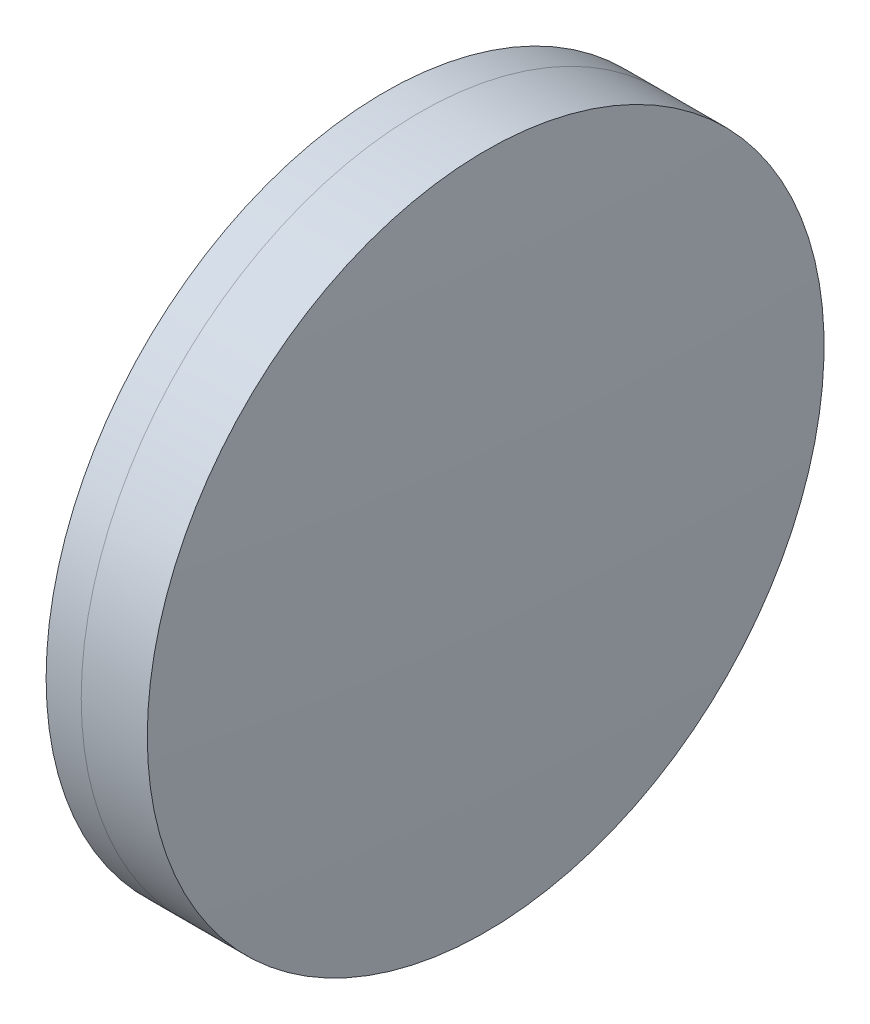
from build123d import *


with BuildPart() as part:
    # 草图1 one side → 旋转1 (revolve)
    with BuildSketch(Plane(origin=(0, 0, 0), x_dir=(1, 0, 0), z_dir=(0, 1, 0)), mode=Mode.PRIVATE) as revolve_1_sk:
        with BuildLine():
            ThreePointArc((77.514489477, 12.5), (76.920073035, 6.262558669), (76.721668974, 0))
            Line((76.721668974, 0), (80.021668974, 0))
            ThreePointArc((80.021668974, 0), (79.718324925, 6.279240278), (78.811117917, 12.5))
            Line((78.811117917, 12.5), (77.514489477, 12.5))
        make_face()
    revolve(revolve_1_sk.sketch.rotate(Axis((-9.702612178, 0, 0), (1, 0, 0)), 180), axis=Axis((-9.702612178, 0, 0), (1, 0, 0)))  # turned: the seam where the file's is


with BuildPart() as body_2:
    # 草图2 one side → 旋转3 (revolve)
    with BuildSketch(Plane(origin=(0, 0, 0), x_dir=(1, 0, 0), z_dir=(0, 1, 0)), mode=Mode.PRIVATE) as revolve_3_sk:
        with BuildLine():
            Line((81.251844892, 12.5), (78.811117917, 12.5))
            ThreePointArc((78.811117917, 12.5), (79.718324925, 6.279240278), (80.021668974, 0))
            Line((80.021668974, 0), (81.621668974, 0))
            ThreePointArc((81.621668974, 0), (81.52919273, 6.252734799), (81.251844892, 12.5))
        make_face()
    revolve(revolve_3_sk.sketch.rotate(Axis((-0.551919993, 0, 0), (1, 0, 0)), 180), axis=Axis((-0.551919993, 0, 0), (1, 0, 0)))  # turned: the seam where the file's is


solid = Compound([part.part, body_2.part])
